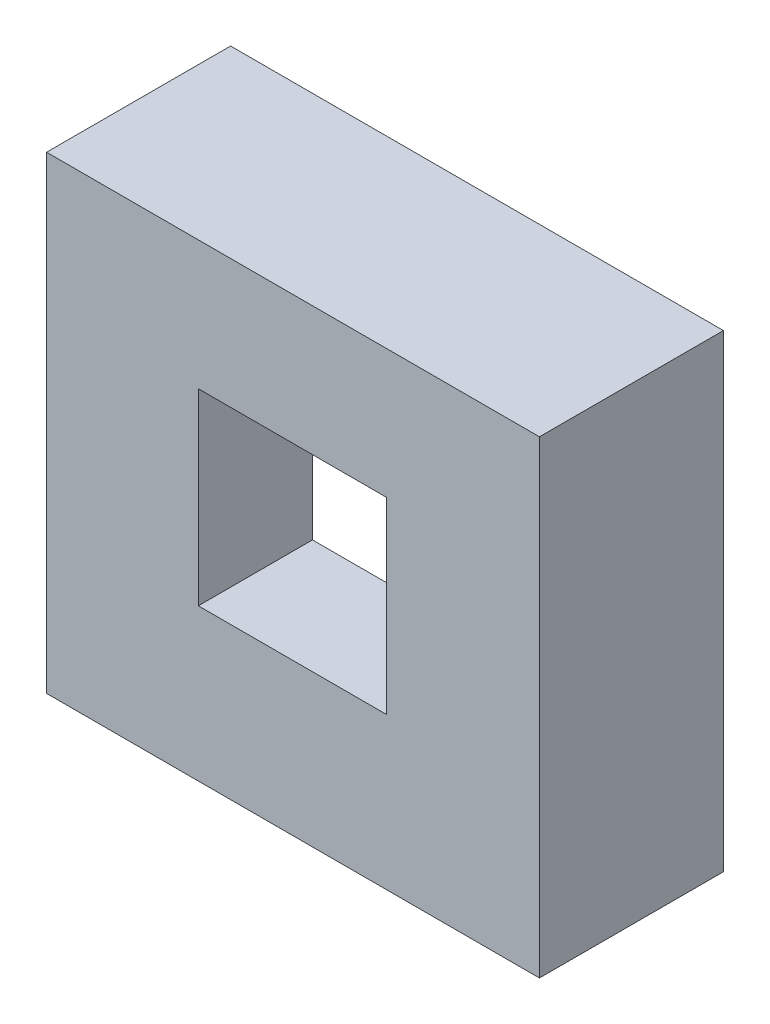
from build123d import *

# Parameters (mm, degrees)
SKETCH1_W           = 36.7
SKETCH1_H           = 34.9
SKETCH1_W_2         = 34.7
SKETCH1_H_2         = 32.9
BOSS_EXTRUDE1_DEPTH = 11.2
SKETCH2_W           = 4.9
SKETCH2_H           = 1
CUT_EXTRUDE1_DEPTH  = 1.9
SKETCH4_W           = 36.7
SKETCH4_H           = 34.9
BOSS_EXTRUDE3_DEPTH = 2.5
SKETCH5_W           = 14
SKETCH5_H           = 14
CUT_EXTRUDE2_DEPTH  = 14.7
SKETCH6_W           = 16
SKETCH6_H           = 16
SKETCH6_W_2         = 14
SKETCH6_H_2         = 14
BOSS_EXTRUDE4_DEPTH = 6


with BuildPart() as part:
    # Sketch1 → Boss-Extrude1 (new body)
    with BuildSketch(Plane.XY):
        with Locations((18.35, 17.45)):
            Rectangle(SKETCH1_W, SKETCH1_H)
        with Locations((18.35, 17.45)):
            Rectangle(SKETCH1_W_2, SKETCH1_H_2, mode=Mode.SUBTRACT)
    extrude(amount=BOSS_EXTRUDE1_DEPTH)

    # Sketch2 → Cut-Extrude1 (cut)
    with BuildSketch(Plane(origin=(0, 0, 0), x_dir=(-1, 0, 0), z_dir=(0, 0, -1))):
        with Locations((-28.25, 0.5)):
            Rectangle(SKETCH2_W, SKETCH2_H)
    extrude(amount=-CUT_EXTRUDE1_DEPTH, mode=Mode.SUBTRACT)

    # Sketch4 → Boss-Extrude3 (add)
    with BuildSketch(Plane.XY.offset(11.2)):
        with Locations((18.35, 17.45)):
            Rectangle(SKETCH4_W, SKETCH4_H)
    extrude(amount=BOSS_EXTRUDE3_DEPTH)

    # Sketch5 → Cut-Extrude2 (cut, through all)
    with BuildSketch(Plane.XY.offset(13.7)):
        with Locations((18.3, 18.3)):
            Rectangle(SKETCH5_W, SKETCH5_H)
    extrude(amount=-CUT_EXTRUDE2_DEPTH, mode=Mode.SUBTRACT)

    # Sketch6 → Boss-Extrude4 (add)
    with BuildSketch(Plane(origin=(0, 0, 11.2), x_dir=(-1, 0, 0), z_dir=(0, 0, -1))):
        with Locations((-18.3, 18.3)):
            Rectangle(SKETCH6_W, SKETCH6_H)
        with Locations((-18.3, 18.3)):
            Rectangle(SKETCH6_W_2, SKETCH6_H_2, mode=Mode.SUBTRACT)
    extrude(amount=BOSS_EXTRUDE4_DEPTH)


solid = part.part
